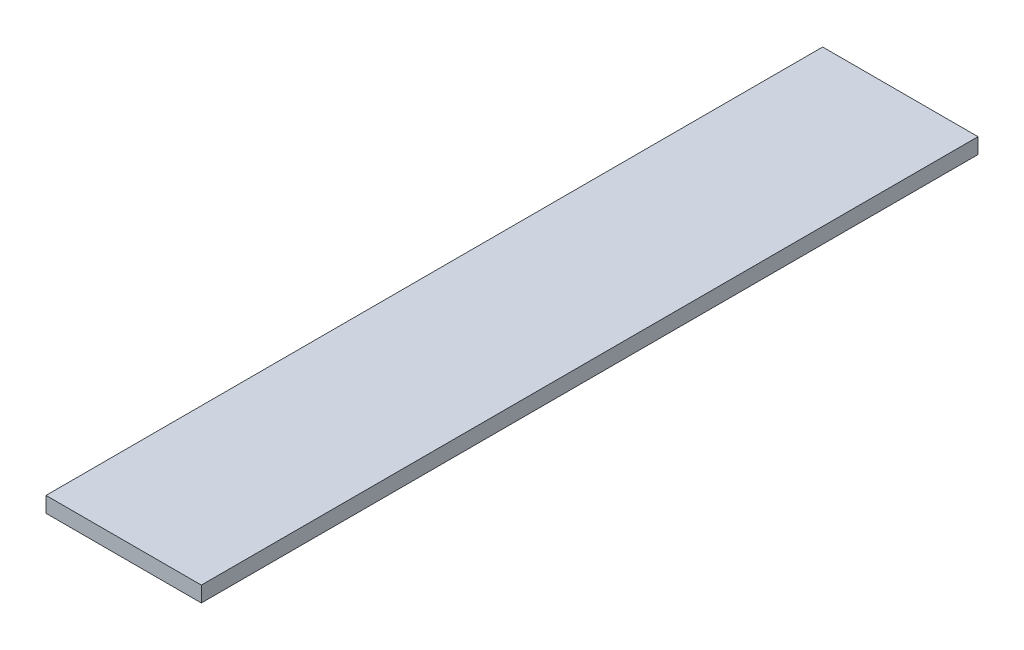
from build123d import *

# Parameters (mm, degrees)
SKETCH1_W           = 200
SKETCH1_H           = 1000
BOSS_EXTRUDE1_DEPTH = 20


with BuildPart() as part:
    # Sketch1 → Boss-Extrude1 (new body)
    with BuildSketch(Plane(origin=(0, 0, 0), x_dir=(1, 0, 0), z_dir=(0, 1, 0))):
        with Locations((100, 500)):
            Rectangle(SKETCH1_W, SKETCH1_H)
    extrude(amount=BOSS_EXTRUDE1_DEPTH)


solid = part.part
